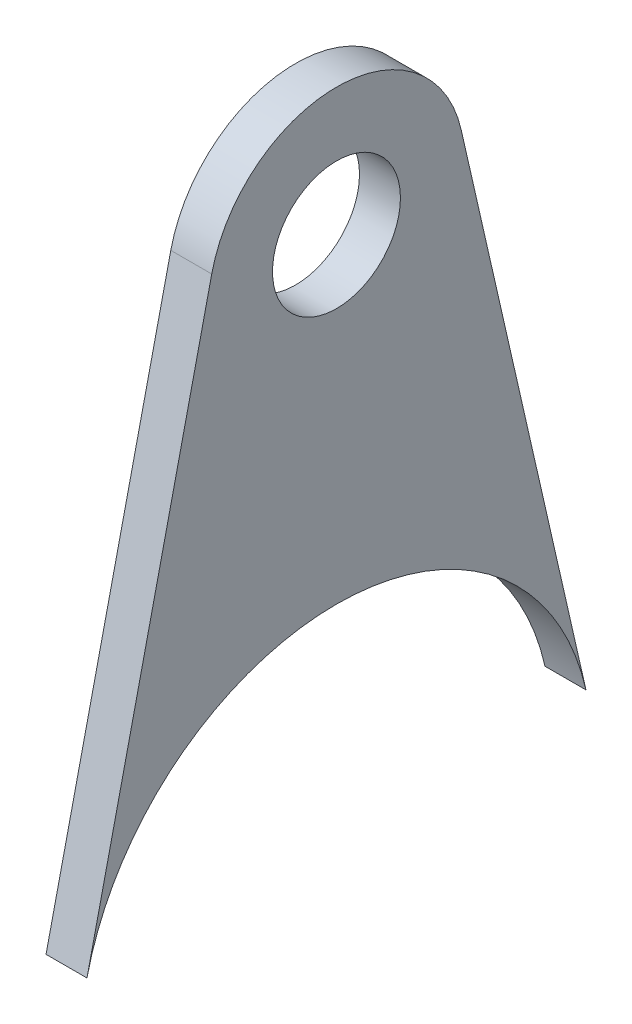
from build123d import *

# Parameters (mm, degrees)
BOSS_EXTRUDE1_DEPTH = 1.016
SKETCH2_R           = 3.175
CUT_EXTRUDE1_DEPTH  = 3.032


with BuildPart() as part:
    # Sketch1 → Boss-Extrude1 (new body, symmetric)
    with BuildSketch(Plane(origin=(0, 0, 0), x_dir=(0, 0, -1), z_dir=(1, 0, 0))):
        with BuildLine():
            Line((-12.382449747, -9.877777778), (-6.191224873, 17.286111111))
            ThreePointArc((-6.191224873, 17.286111111), (0, 22.225), (6.191224873, 17.286111111))
            Line((6.191224873, 17.286111111), (12.382449747, -9.877777778))
            ThreePointArc((12.382449747, -9.877777778), (0, 0), (-12.382449747, -9.877777778))
        make_face()
    extrude(amount=BOSS_EXTRUDE1_DEPTH, both=True)

    # Sketch2 → Cut-Extrude1 (cut, through all)
    with BuildSketch(Plane(origin=(1.016, 0, 0), x_dir=(0, 0, -1), z_dir=(1, 0, 0))):
        with Locations((0, 15.875)):
            Circle(SKETCH2_R)
    extrude(amount=-CUT_EXTRUDE1_DEPTH, mode=Mode.SUBTRACT)


solid = part.part
